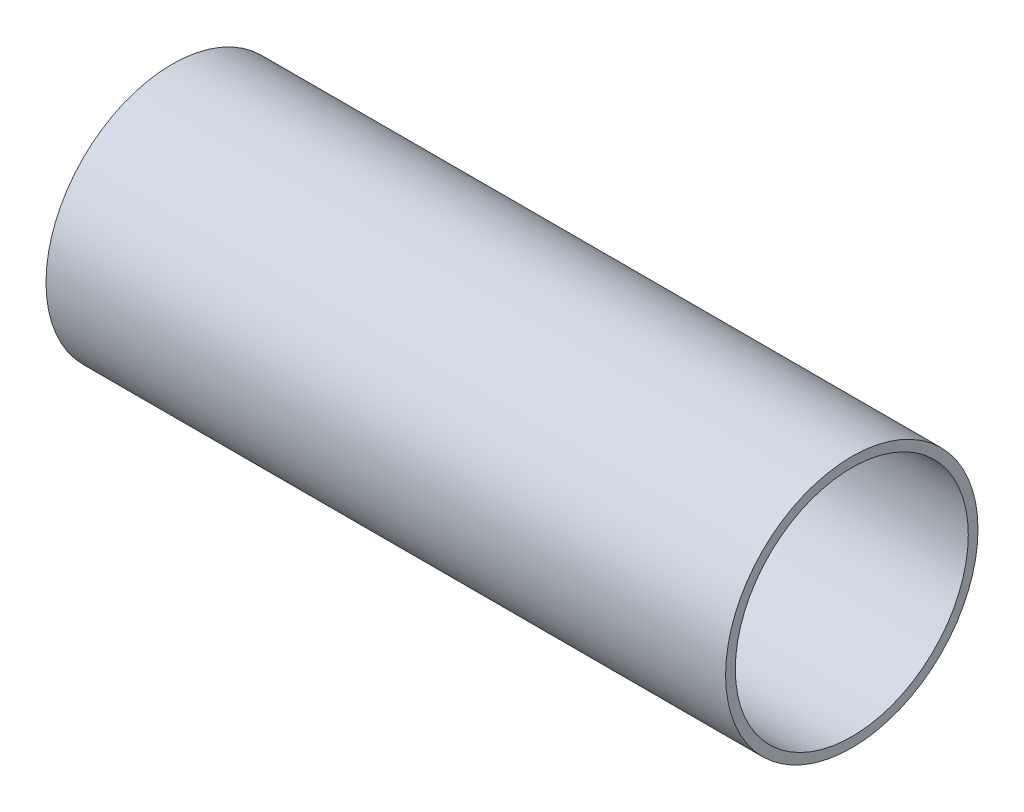
from build123d import *

# Parameters (mm, degrees)
SKETCH_1_R      = 65
SKETCH_1_R_2    = 60
EXTRUDE_1_DEPTH = 350


with BuildPart() as part:
    # Эскиз1 → Бобышка-Вытянуть1 (new body)
    with BuildSketch(Plane(origin=(0, 0, 0), x_dir=(0, 0, -1), z_dir=(1, 0, 0))):
        Circle(SKETCH_1_R)
        Circle(SKETCH_1_R_2, mode=Mode.SUBTRACT)
    extrude(amount=EXTRUDE_1_DEPTH)


solid = part.part
